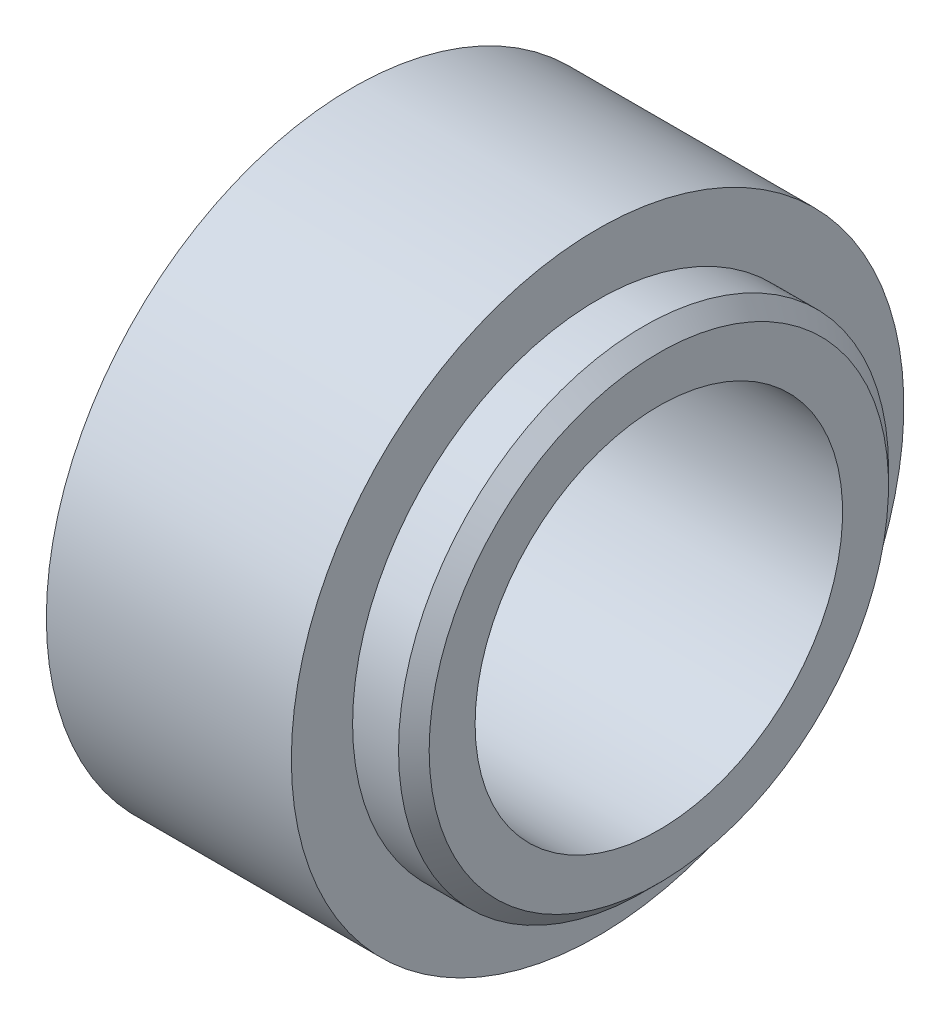
from build123d import *


with BuildPart() as part:
    # Sketch1 → Revolve1 (revolve)
    with BuildSketch(Plane.XY):
        Polygon((9.092045455, 19.05), (20.348863636, 19.05), (20.348863636, 23.8125), (18.761363636, 25.4), (13.998863636, 25.4), (13.998863636, 31.75), (-11.401136364, 31.75), (-11.401136364, 20.6375), (-9.813636364, 19.05), align=None)
    revolve(axis=Axis((-20.6375, 0, 0), (1, 0, 0)))


solid = part.part
